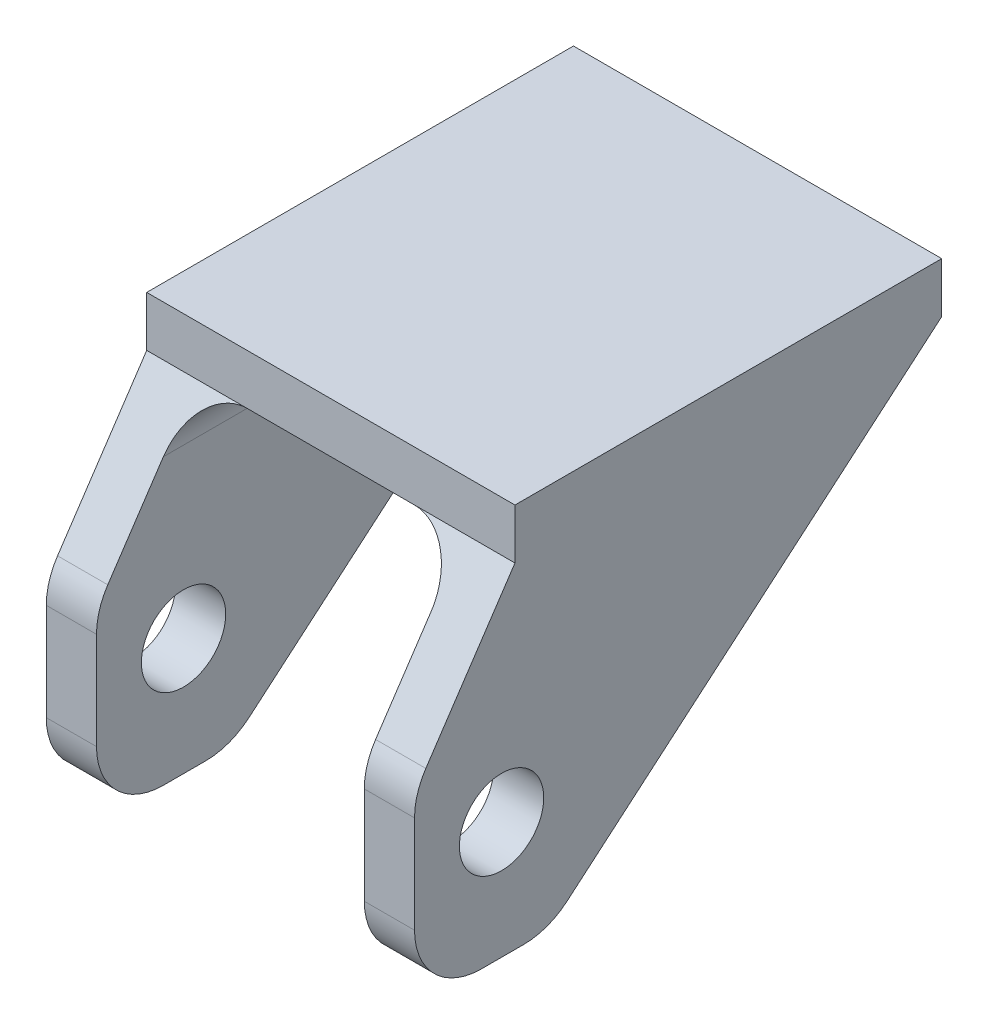
from build123d import *

# Parameters (mm, degrees)
SKETCH1_W           = 4.7625
SKETCH1_H           = 50
SKETCH1_W_2         = 25.4
BOSS_EXTRUDE1_DEPTH = 4.7625
SKETCH1_3_W         = 4.7625
SKETCH1_3_H         = 50
BOSS_EXTRUDE2_DEPTH = 31.75
SKETCH3_R           = 4
CUT_EXTRUDE1_DEPTH  = 35.925
FILLET1_R           = 6.35
FILLET2_R           = 4.7625


with BuildPart() as part:
    # Sketch1 → Boss-Extrude1 (new body)
    with BuildSketch(Plane(origin=(0, 0, 0), x_dir=(1, 0, 0), z_dir=(0, 1, 0))):
        with Locations((-15.08125, 0)):
            Rectangle(SKETCH1_W, SKETCH1_H)
        Rectangle(SKETCH1_W_2, SKETCH1_H)
        with Locations((15.08125, 0)):
            Rectangle(SKETCH1_W, SKETCH1_H)
    extrude(amount=BOSS_EXTRUDE1_DEPTH)

    # Sketch1_3 → Boss-Extrude2 (add)
    with BuildSketch(Plane(origin=(0, 0, 0), x_dir=(1, 0, 0), z_dir=(0, 1, 0))):
        with Locations((-15.08125, 0)):
            Rectangle(SKETCH1_3_W, SKETCH1_3_H)
        with Locations((15.08125, 0)):
            Rectangle(SKETCH1_3_W, SKETCH1_3_H)
    extrude(amount=-BOSS_EXTRUDE2_DEPTH)

    # Sketch3 → Cut-Extrude1 (cut, through all)
    with BuildSketch(Plane(origin=(17.4625, 0, 0), x_dir=(0, 0, -1), z_dir=(1, 0, 0))):
        Polygon((25, -31.75), (25, 0), (-12.3, -31.75), align=None)
        Polygon((-15.475, 0), (-15.475, 4.7625), (-25, 4.7625), (-25, 0), (-25, -14.247596398), align=None)
        with Locations((-16.745, -20.6375)):
            Circle(SKETCH3_R)
    extrude(amount=-CUT_EXTRUDE1_DEPTH, mode=Mode.SUBTRACT)

    # Fillet1
    fillet1_edges = [part.edges().sort_by_distance(p)[0] for p in [
        (-15.08125, -31.75, 25),
        (15.08125, -31.75, 25),
        (15.08125, -31.75, 12.3),
        (-15.08125, -31.75, 12.3),
        (15.08125, -14.247596398, 25),
        (-15.08125, -14.247596398, 25),
    ]]
    fillet(fillet1_edges, radius=FILLET1_R)

    # Fillet2
    fillet2_edges = [part.edges().sort_by_distance(p)[0] for p in [
        (12.7, 0, -4.7625),
        (-12.7, 0, -4.7625),
    ]]
    fillet(fillet2_edges, radius=FILLET2_R)


solid = part.part
